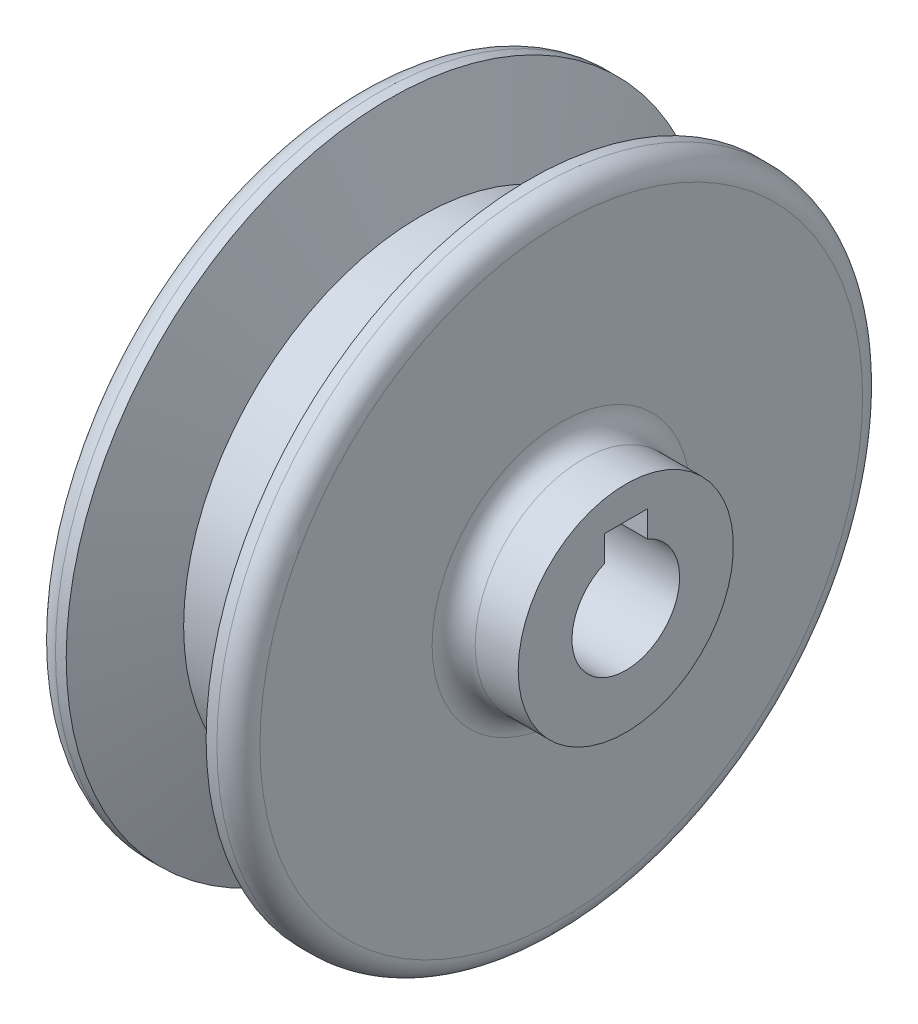
from build123d import *

# Parameters (mm, degrees)
SKETCH2_W          = 4
SKETCH2_H          = 7
CUT_EXTRUDE1_DEPTH = 40


with BuildPart() as part:
    # Sketch1 → Revolve1 (revolve)
    with BuildSketch(Plane.XY):
        with BuildLine():
            Line((16, 30), (17, 30))
            ThreePointArc((17, 30), (18.414213562, 29.414213562), (19, 28))
            Line((19, 28), (19, 12))
            ThreePointArc((19, 12), (19.585786438, 10.585786438), (21, 10))
            Line((21, 10), (25, 10))
            Line((25, 10), (25, 5))
            Line((25, 5), (0, 5))
            Line((0, 5), (0, 28))
            ThreePointArc((0, 28), (0.585786438, 29.414213562), (2, 30))
            Line((2, 30), (3, 30))
            Line((3, 30), (5.911761874, 22))
            Line((5.911761874, 22), (13.088238126, 22))
            Line((13.088238126, 22), (16, 30))
        make_face()
    revolve(axis=Axis((-3.782421274, 0, 0), (1, 0, 0)))

    # Sketch2 → Cut-Extrude1 (cut)
    with BuildSketch(Plane(origin=(25, 0, 0), x_dir=(0, 0, -1), z_dir=(1, 0, 0))):
        with Locations((0, 3.5)):
            Rectangle(SKETCH2_W, SKETCH2_H)
    extrude(amount=-CUT_EXTRUDE1_DEPTH, mode=Mode.SUBTRACT)


solid = part.part
